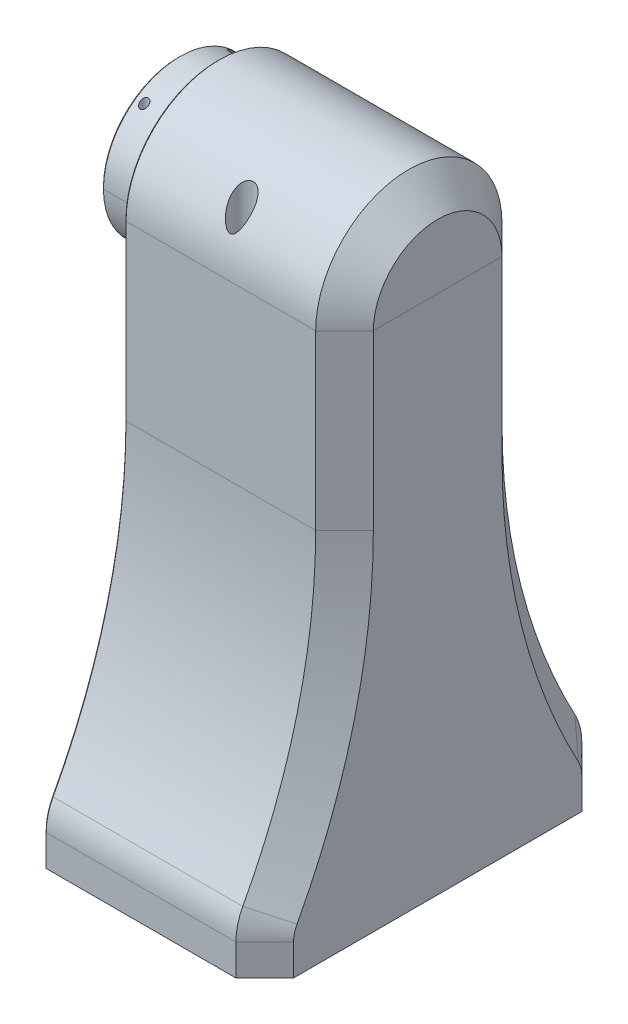
from build123d import *

# Parameters (mm, degrees)
CUT_EXTRUDE1_START             = -33.528
CUT_EXTRUDE1_DEPTH             = 15.732
BOSS_EXTRUDE1_START            = 8.6106
BOSS_EXTRUDE1_DEPTH            = 48.514
SKETCH4_R                      = 16.8783
BOSS_EXTRUDE2_DEPTH            = 8.6106
CHAMFER1_SIZE                  = 6.35
SKETCH9_R                      = 0.889
CUT_EXTRUDE5_DEPTH             = 21.5232
CUT_EXTRUDE5_DEPTH_BACK        = 115.681
CHAMFER2_SIZE                  = 0.381
CUT_EXTRUDE2_DEPTH             = 115.681
CUT_EXTRUDE4_START             = -30.48
CUT_EXTRUDE4_DEPTH             = 85.2010001
CUT_EXTRUDE3_DEPTH             = 22.86
FILLET2_R                      = 3.81
M5X0_8_TAPPED_HOLE1_AT_2_COUNT = 2
M5X0_8_TAPPED_HOLE1_AT_2_PITCH = 31.75
CUT_EXTRUDE6_START             = 4.572
SKETCH13_R                     = 2.54
CUT_EXTRUDE6_DEPTH             = 16.9512
SKETCH15_W                     = 1.1
SKETCH15_H                     = 119.253


with BuildPart() as part:
    # Sketch1 → Revolve1 (revolve)
    with BuildSketch(Plane.XY):
        Polygon((0, 0), (0, 5.0292), (5.0546, 5.0292), (5.0546, 13.7668), (36.8046, 13.7668), (36.8046, 14.224), (40.6146, 14.224), (40.6146, 13.7668), (43.1546, 13.7668), (43.1546, 13.7414), (53.3146, 13.7414), (53.3146, 0), align=None)
    revolve(axis=Axis((53.3146, 0, 0), (-1, 0, 0)))

    # Sketch2 → Cut-Extrude1 (cut, through all)
    with BuildSketch(Plane.ZY.offset(-5.0546).offset(CUT_EXTRUDE1_START)):
        with BuildLine():
            Line((-1.4224, -14.6304), (-1.4224, -12.9032))
            ThreePointArc((-1.4224, -12.9032), (0, -11.4808), (1.4224, -12.9032))
            Line((1.4224, -12.9032), (1.4224, -14.6304))
            ThreePointArc((1.4224, -14.6304), (0, -16.0528), (-1.4224, -14.6304))
        make_face()
        with BuildLine():
            Line((1.4224, 14.6304), (1.4224, 12.9032))
            ThreePointArc((1.4224, 12.9032), (0, 11.4808), (-1.4224, 12.9032))
            Line((-1.4224, 12.9032), (-1.4224, 14.6304))
            ThreePointArc((-1.4224, 14.6304), (0, 16.0528), (1.4224, 14.6304))
        make_face()
    extrude(amount=-CUT_EXTRUDE1_DEPTH, mode=Mode.SUBTRACT)


with BuildPart() as body_2:
    # Sketch3 → Boss-Extrude1 (new body)
    with BuildSketch(Plane(origin=(0, 0, 0), x_dir=(0, 0, -1), z_dir=(1, 0, 0)).offset(BOSS_EXTRUDE1_START)):
        with BuildLine():
            Line((0, -114.681), (38.1, -114.681))
            Line((38.1, -114.681), (38.1, -107.800788812))
            ThreePointArc((38.1, -107.800788812), (37.714481696, -104.695383757), (36.581332196, -101.778512638))
            ThreePointArc((36.581332196, -101.778512638), (24.599604248, -70.936019024), (20.5232, -38.1))
            Line((20.5232, -38.1), (20.5232, 0))
            ThreePointArc((20.5232, 0), (14.512093892, 14.512093892), (0, 20.5232))
            Line((0, 20.5232), (0, -114.681))
        make_face()
    extrude(amount=BOSS_EXTRUDE1_DEPTH)

    # Sketch4 → Boss-Extrude2 (add)
    with BuildSketch(Plane.ZY.offset(-8.6106)):
        Circle(SKETCH4_R)
    extrude(amount=BOSS_EXTRUDE2_DEPTH)

    # Combine1: cut part
    add(part.part, mode=Mode.SUBTRACT)

    # Chamfer1
    chamfer1_edges = [body_2.edges().sort_by_distance(p)[0] for p in [
        (57.1246, -111.240894406, -38.1),
        (57.1246, -19.05, -20.5232),
        (57.1246, -70.936019024, -24.599604248),
        (57.1246, -104.695383757, -37.714481696),
        (57.1246, 14.512093892, -14.512093892),
    ]]
    chamfer(chamfer1_edges, length=CHAMFER1_SIZE)

    # Sketch9 → Cut-Extrude5 (cut, two sides)
    with BuildSketch(Plane(origin=(0, 0, 0), x_dir=(1, 0, 0), z_dir=(0, 1, 0))) as cut_extrude5_sk:
        with Locations((2.286, 9.779)):
            Circle(SKETCH9_R)
        with Locations((2.286, -9.779)):
            Circle(SKETCH9_R)
    extrude(amount=CUT_EXTRUDE5_DEPTH, mode=Mode.SUBTRACT)
    extrude(cut_extrude5_sk.sketch, amount=-CUT_EXTRUDE5_DEPTH_BACK, mode=Mode.SUBTRACT)

    # Chamfer2
    chamfer2_edges = [body_2.edges().sort_by_distance(p)[0] for p in [
        (8.6106, -104.695383757, -37.714481696),
        (8.6106, -111.240894406, -38.1),
        (8.6106, -19.05, -20.5232),
        (0, 0, -16.8783),
        (8.6106, -70.936019024, -24.599604248),
        (0, -5.0292, 0),
        (5.0546, -5.0292, 0),
        (8.6106, 14.512093892, -14.512093892),
    ]]
    chamfer(chamfer2_edges, length=CHAMFER2_SIZE)


with BuildPart() as body_2_2:
    # Split1: the piece on the far side of the plane
    add(body_2.part)
    split(bisect_by=Plane.ZX, keep=Keep.BOTTOM)

    # Sketch5 → Cut-Extrude2 (cut, through all)
    with BuildSketch(Plane(origin=(0, 0, 0), x_dir=(1, 0, 0), z_dir=(0, 1, 0))):
        with BuildLine():
            Line((13.6906, 0), (36.0426, 0))
            Line((36.0426, 0), (36.0426, 8.6868))
            ThreePointArc((36.0426, 8.6868), (35.298651224, 10.482851224), (33.5026, 11.2268))
            Line((33.5026, 11.2268), (16.2306, 11.2268))
            ThreePointArc((16.2306, 11.2268), (14.434548776, 10.482851224), (13.6906, 8.6868))
            Line((13.6906, 8.6868), (13.6906, 0))
        make_face()
    extrude(amount=-CUT_EXTRUDE2_DEPTH, mode=Mode.SUBTRACT)

    # Sketch7 → Cut-Extrude4 (cut, through all)
    with BuildSketch(Plane(origin=(0, 0, 0), x_dir=(1, 0, 0), z_dir=(0, 1, 0)).offset(CUT_EXTRUDE4_START)):
        with BuildLine():
            Line((33.5026, 11.2268), (49.5046, 11.2268))
            ThreePointArc((49.5046, 11.2268), (51.300651224, 10.482851224), (52.0446, 8.6868))
            Line((52.0446, 8.6868), (52.0446, 0))
            Line((52.0446, 0), (33.5026, 0))
            Line((33.5026, 0), (33.5026, 11.2268))
        make_face()
    extrude(amount=-CUT_EXTRUDE4_DEPTH, mode=Mode.SUBTRACT)

    # Sketch6 → Cut-Extrude3 (cut)
    with BuildSketch(Plane(origin=(0, 0, 0), x_dir=(1, 0, 0), z_dir=(0, 1, 0))):
        with BuildLine():
            Line((33.5026, 11.2268), (50.7746, 11.2268))
            ThreePointArc((50.7746, 11.2268), (52.570651224, 10.482851224), (53.3146, 8.6868))
            Line((53.3146, 8.6868), (53.3146, 7.4168))
            ThreePointArc((53.3146, 7.4168), (52.570651224, 5.620748776), (50.7746, 4.8768))
            Line((50.7746, 4.8768), (33.5026, 4.8768))
            Line((33.5026, 4.8768), (33.5026, 11.2268))
        make_face()
    extrude(amount=-CUT_EXTRUDE3_DEPTH, mode=Mode.SUBTRACT)

    # Fillet2
    fillet2_edges = [body_2_2.edges().sort_by_distance(p)[0] for p in [
        (36.0426, -17.867033556, -4.8768),
    ]]
    fillet(fillet2_edges, radius=FILLET2_R)

    # Sketch12 → M5x0.8 Tapped Hole1 (revolve, cut)
    with BuildSketch(Plane(origin=(19.0246, -114.681, -30.48), x_dir=(0, 0, -1), z_dir=(1, 0, 0))):
        Polygon((0, 0), (0, 16.2478073), (2.1, 14.986), (2.1, 0), align=None)
    m5x0_8_tapped_hole1 = revolve(axis=Axis((19.0246, -121.031, -30.48), (0, 1, 0)), mode=Mode.SUBTRACT)

    # M5x0.8 Tapped Hole1 at 2: M5x0.8 Tapped Hole1 ×2
    with Locations(*[(i * M5X0_8_TAPPED_HOLE1_AT_2_PITCH, 0, 0) for i in range(1, M5X0_8_TAPPED_HOLE1_AT_2_COUNT)]):
        add(m5x0_8_tapped_hole1, mode=Mode.SUBTRACT)

    # Sketch17 → M2x0.4 Tapped Hole1 (revolve, cut)
    with BuildSketch(Plane(origin=(30.48, 0, -16.51), x_dir=(0, 0, 1), z_dir=(1, 0, 0))):
        Polygon((0, 0), (0, 14.450688495), (0.8, 13.97), (0.8, 0), align=None)
    revolve(axis=Axis((30.48, 6.35, -16.51), (0, -1, 0)), mode=Mode.SUBTRACT)

    # Mirror1: body 2 2 across plane


with BuildPart() as body_2_1:
    add(body_2.part)

    # Split1
    split(bisect_by=Plane.ZX, keep=Keep.TOP)

    # Sketch13 → Cut-Extrude6 (cut, through all)
    with BuildSketch(Plane(origin=(0, 0, 0), x_dir=(1, 0, 0), z_dir=(0, 1, 0)).offset(CUT_EXTRUDE6_START)):
        with Locations((30.48, 16.51)):
            Circle(SKETCH13_R)
    extrude(amount=CUT_EXTRUDE6_DEPTH, mode=Mode.SUBTRACT)

    # Sketch15 → M2 Clearance Hole1 (revolve, cut)
    with BuildSketch(Plane(origin=(30.48, 4.572, -16.51), x_dir=(0, 0, 1), z_dir=(1, 0, 0))):
        with Locations((0.55, 59.6265)):
            Rectangle(SKETCH15_W, SKETCH15_H)
    revolve(axis=Axis((30.48, 10.922, -16.51), (0, -1, 0)), mode=Mode.SUBTRACT)

    # Mirror1 2: body 2 across plane


with BuildPart() as body_2_2_1:
    add(body_2_2.part)
    add(body_2_2.part.mirror(Plane.XY))


with BuildPart() as body_2_3:
    add(body_2_1.part)
    add(body_2_1.part.mirror(Plane.XY))


solid = Compound([body_2_2_1.part, body_2_3.part])
